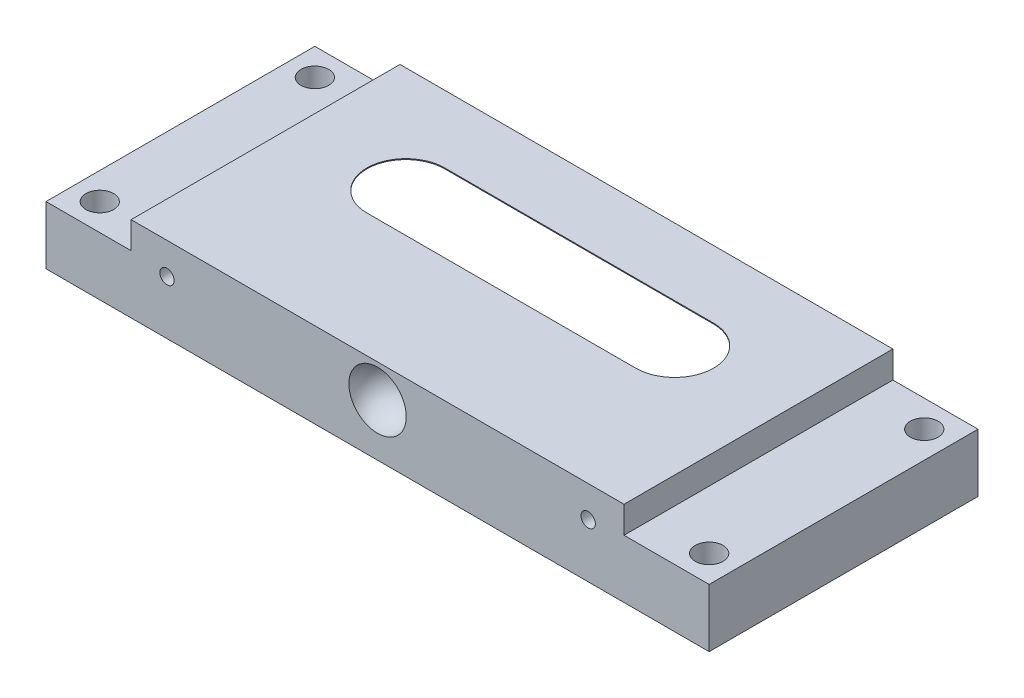
from build123d import *

# Parameters (mm, degrees)
SKETCH1_W                                       = 74
SKETCH1_H                                       = 30
BOSS_EXTRUDE1_DEPTH                             = 9.5
SKETCH2_W                                       = 9.5
SKETCH2_H                                       = 30
CUT_EXTRUDE1_DEPTH                              = 3
CSK_FOR_M3_FLAT_HEAD_MACHINE_SCREW1_D           = 3.1
CSK_FOR_M3_FLAT_HEAD_MACHINE_SCREW1_CSINK_D     = 5.4
CSK_FOR_M3_FLAT_HEAD_MACHINE_SCREW1_CSINK_ANGLE = 90
SKETCH14_W                                      = 30
SKETCH14_H                                      = 21.35
SKETCH21_R                                      = 0.8
CUT_EXTRUDE2_DEPTH                              = 6
TAP_DRILL_FOR_M3X0_5_TAP1_D                     = 2.5
TAP_DRILL_FOR_M3X0_5_TAP1_DEPTH                 = 4.5
TAP_DRILL_FOR_M3X0_5_TAP1_TIP                   = 0.751075774
CUT_EXTRUDE3_DEPTH                              = 10


with BuildPart() as part:
    # Sketch1 → Boss-Extrude1 (new body)
    with BuildSketch(Plane(origin=(0, 0, 0), x_dir=(1, 0, 0), z_dir=(0, 1, 0))):
        with Locations((37, 15)):
            Rectangle(SKETCH1_W, SKETCH1_H)
    extrude(amount=BOSS_EXTRUDE1_DEPTH)

    # Sketch2 → Cut-Extrude1 (cut)
    with BuildSketch(Plane(origin=(0, 9.5, 0), x_dir=(1, 0, 0), z_dir=(0, 1, 0))):
        with Locations((69.25, 15)):
            Rectangle(SKETCH2_W, SKETCH2_H)
        with Locations((4.75, 15)):
            Rectangle(SKETCH2_W, SKETCH2_H)
    extrude(amount=-CUT_EXTRUDE1_DEPTH, mode=Mode.SUBTRACT)

    # CSK for M3 Flat Head Machine Screw1 (through all)
    with Locations(Plane(origin=(3, 0, -3), x_dir=(0, 0, -1), z_dir=(0, -1, 0))):
        with Locations((0, 0), (24, 0), (24, 68), (0, 68)):
            CounterSinkHole(CSK_FOR_M3_FLAT_HEAD_MACHINE_SCREW1_D / 2, CSK_FOR_M3_FLAT_HEAD_MACHINE_SCREW1_CSINK_D / 2, counter_sink_angle=CSK_FOR_M3_FLAT_HEAD_MACHINE_SCREW1_CSINK_ANGLE)

    # Sketch12 → Cut-Revolve5 (revolve, cut)
    with BuildSketch(Plane(origin=(0, -11.5, 0), x_dir=(-1, 0, 0), z_dir=(0, -1, 0))):
        with BuildLine():
            Line((-52, -3.2), (-52, 39.5))
            ThreePointArc((-52, 39.5), (-73.35, 18.15), (-52, -3.2))
        make_face()
    revolve(axis=Axis((52, -11.5, 3.2), (0, 0, -1)), mode=Mode.SUBTRACT)

    # Sketch12_8 → Cut-Revolve6 (revolve, cut)
    with BuildSketch(Plane(origin=(0, -11.5, 0), x_dir=(-1, 0, 0), z_dir=(0, -1, 0))):
        with BuildLine():
            Line((-22, -3.2), (-22, 39.5))
            ThreePointArc((-22, 39.5), (-0.65, 18.15), (-22, -3.2))
        make_face()
    revolve(axis=Axis((22, -11.5, 3.2), (0, 0, -1)), mode=Mode.SUBTRACT)

    # Sketch14 → Cut-Revolve7 (revolve, cut)
    with BuildSketch(Plane(origin=(0, -11.5, 0), x_dir=(-1, 0, 0), z_dir=(0, -1, 0))):
        with Locations((-37, 28.825)):
            Rectangle(SKETCH14_W, SKETCH14_H)
    revolve(axis=Axis((52, -11.5, -18.15), (-1, 0, 0)), mode=Mode.SUBTRACT)

    # Sketch20 one side → Cut-Revolve8 (revolve, cut)
    with BuildSketch(Plane.XY):
        with BuildLine():
            ThreePointArc((37, 9), (33.8, 5.8), (37, 2.6))
            Line((37, 2.6), (37, 9))
        make_face()
    revolve(axis=Axis((37, 9, 0), (0, -1, 0)), mode=Mode.SUBTRACT)

    # Sketch21 → Cut-Extrude2 (cut)
    with BuildSketch(Plane.XY):
        with Locations((13.5, 6)):
            Circle(SKETCH21_R)
        with Locations((60.5, 6)):
            Circle(SKETCH21_R)
    extrude(amount=-CUT_EXTRUDE2_DEPTH, mode=Mode.SUBTRACT)

    # Tap Drill for M3x0.5 Tap1
    with Locations(Plane(origin=(6.5, 4.5, -30), x_dir=(-1, 0, 0), z_dir=(0, 0, -1))):
        with Locations((0, 0), (-61, 0)):
            Hole(TAP_DRILL_FOR_M3X0_5_TAP1_D / 2, depth=TAP_DRILL_FOR_M3X0_5_TAP1_DEPTH)
            with Locations((0, 0, -(TAP_DRILL_FOR_M3X0_5_TAP1_DEPTH + TAP_DRILL_FOR_M3X0_5_TAP1_TIP / 2))):  # 118° drill point
                Cone(0, TAP_DRILL_FOR_M3X0_5_TAP1_D / 2, TAP_DRILL_FOR_M3X0_5_TAP1_TIP, mode=Mode.SUBTRACT)

    # Sketch26 → Cut-Extrude3 (cut)
    with BuildSketch(Plane(origin=(0, 9.5, 0), x_dir=(1, 0, 0), z_dir=(0, 1, 0))):
        with BuildLine():
            Line((52, 13.8), (22, 13.8))
            ThreePointArc((22, 13.8), (17.65, 18.15), (22, 22.5))
            Line((22, 22.5), (52, 22.5))
            ThreePointArc((52, 22.5), (56.35, 18.15), (52, 13.8))
        make_face()
    extrude(amount=-CUT_EXTRUDE3_DEPTH, mode=Mode.SUBTRACT)


solid = part.part
